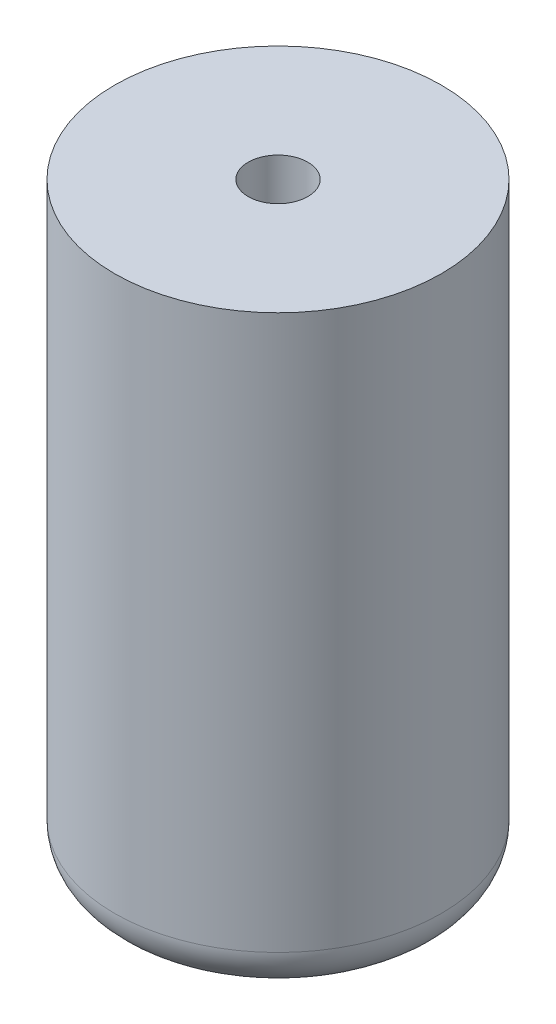
from build123d import *

# Parameters (mm, degrees)
SKETCH1_R           = 11.5
BOSS_EXTRUDE1_DEPTH = 42
FILLET1_R           = 3
SKETCH3_R           = 2.1
CUT_EXTRUDE1_DEPTH  = 10


with BuildPart() as part:
    # Sketch1 → Boss-Extrude1 (new body)
    with BuildSketch(Plane(origin=(0, 0, 0), x_dir=(1, 0, 0), z_dir=(0, 1, 0))):
        Circle(SKETCH1_R)
    extrude(amount=BOSS_EXTRUDE1_DEPTH)

    # Fillet1
    fillet1_edges = [part.edges().sort_by_distance(p)[0] for p in [
        (-11.5, 0, 0),
    ]]
    fillet(fillet1_edges, radius=FILLET1_R)

    # Sketch3 → Cut-Extrude1 (cut)
    with BuildSketch(Plane(origin=(0, 42, 0), x_dir=(1, 0, 0), z_dir=(0, 1, 0))):
        Circle(SKETCH3_R)
    extrude(amount=-CUT_EXTRUDE1_DEPTH, mode=Mode.SUBTRACT)


solid = part.part
